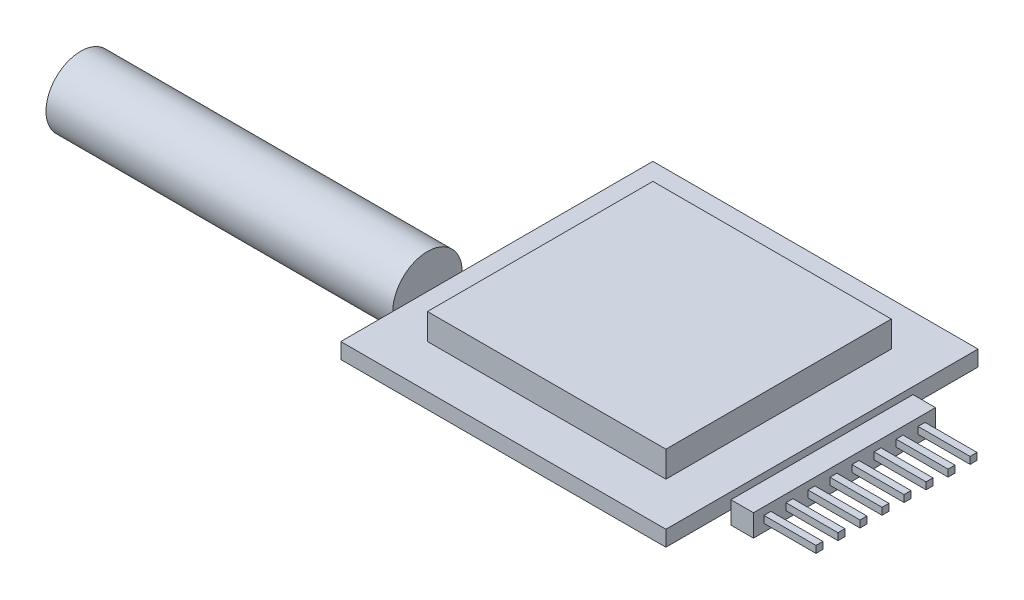
from build123d import *

# Parameters (mm, degrees)
CROQUIS1_W              = 37.5
CROQUIS1_H              = 36
SALIENTE_EXTRUIR1_DEPTH = 1.8
CROQUIS2_W              = 27.5
CROQUIS2_H              = 26
SALIENTE_EXTRUIR2_DEPTH = 3
CROQUIS3_W              = 21
CROQUIS3_H              = 2.54
SALIENTE_EXTRUIR3_DEPTH = 2.6
CROQUIS4_W              = 0.8
CROQUIS4_H              = 0.8
SALIENTE_EXTRUIR4_DEPTH = 6
CROQUIS5_R              = 4
SALIENTE_EXTRUIR5_DEPTH = 40


with BuildPart() as part:
    # Croquis1 → Saliente-Extruir1 (new body)
    with BuildSketch(Plane(origin=(0, 0, 0), x_dir=(1, 0, 0), z_dir=(0, 1, 0))):
        with Locations((18.75, 18)):
            Rectangle(CROQUIS1_W, CROQUIS1_H)
    extrude(amount=SALIENTE_EXTRUIR1_DEPTH)

    # Croquis2 → Saliente-Extruir2 (add)
    with BuildSketch(Plane(origin=(0, 1.8, 0), x_dir=(1, 0, 0), z_dir=(0, 1, 0))):
        with Locations((18.75, 18)):
            Rectangle(CROQUIS2_W, CROQUIS2_H)
    extrude(amount=SALIENTE_EXTRUIR2_DEPTH)

    # Croquis3 → Saliente-Extruir3 (add)
    with BuildSketch(Plane(origin=(37.5, 0, 0), x_dir=(0, 0, -1), z_dir=(1, 0, 0))):
        with Locations((18, -0.27)):
            Rectangle(CROQUIS3_W, CROQUIS3_H)
    extrude(amount=SALIENTE_EXTRUIR3_DEPTH)

    # Croquis4 → Saliente-Extruir4 (add)
    with BuildSketch(Plane(origin=(40.1, 0, 0), x_dir=(0, 0, -1), z_dir=(1, 0, 0))):
        with Locations((21.81, -0.27)):
            Rectangle(CROQUIS4_W, CROQUIS4_H)
        with Locations((19.27, -0.27)):
            Rectangle(CROQUIS4_W, CROQUIS4_H)
        with Locations((16.73, -0.27)):
            Rectangle(CROQUIS4_W, CROQUIS4_H)
        with Locations((24.35, -0.27)):
            Rectangle(CROQUIS4_W, CROQUIS4_H)
        with Locations((26.89, -0.27)):
            Rectangle(CROQUIS4_W, CROQUIS4_H)
        with Locations((14.19, -0.27)):
            Rectangle(CROQUIS4_W, CROQUIS4_H)
        with Locations((11.65, -0.27)):
            Rectangle(CROQUIS4_W, CROQUIS4_H)
        with Locations((9.11, -0.27)):
            Rectangle(CROQUIS4_W, CROQUIS4_H)
    extrude(amount=SALIENTE_EXTRUIR4_DEPTH)

    # Croquis5 → Saliente-Extruir5 (add)
    with BuildSketch(Plane.ZY):
        with Locations((-10, 1.8)):
            Circle(CROQUIS5_R)
    extrude(amount=SALIENTE_EXTRUIR5_DEPTH)


solid = part.part
